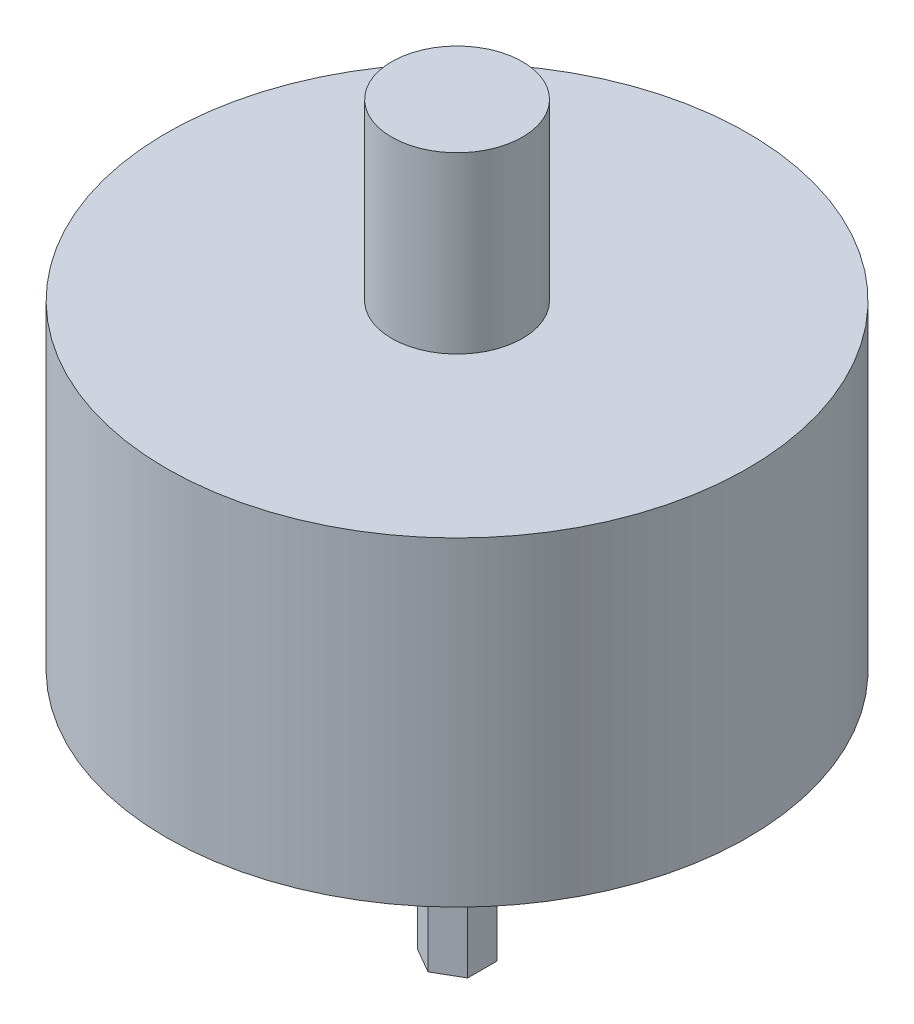
from build123d import *

# Parameters (mm, degrees)
BOSS_EXTRUDE1_DEPTH = 8.5
SKETCH2_R           = 10
BOSS_EXTRUDE2_DEPTH = 11
SKETCH3_R           = 2.25
BOSS_EXTRUDE3_DEPTH = 6


with BuildPart() as part:
    # Sketch1 → Boss-Extrude1 (new body)
    with BuildSketch(Plane(origin=(0, 0, 0), x_dir=(1, 0, 0), z_dir=(0, 1, 0))):
        Polygon((0, 1), (-0.866025404, 0.5), (-0.866025404, -0.5), (0, -1), (0.866025404, -0.5), (0.866025404, 0.5), align=None)
    extrude(amount=BOSS_EXTRUDE1_DEPTH)

    # Sketch2 → Boss-Extrude2 (add)
    with BuildSketch(Plane(origin=(0, 8.5, 0), x_dir=(1, 0, 0), z_dir=(0, 1, 0))):
        Circle(SKETCH2_R)
    extrude(amount=BOSS_EXTRUDE2_DEPTH)

    # Sketch3 → Boss-Extrude3 (add)
    with BuildSketch(Plane(origin=(0, 19.5, 0), x_dir=(1, 0, 0), z_dir=(0, 1, 0))):
        Circle(SKETCH3_R)
    extrude(amount=BOSS_EXTRUDE3_DEPTH)


solid = part.part
